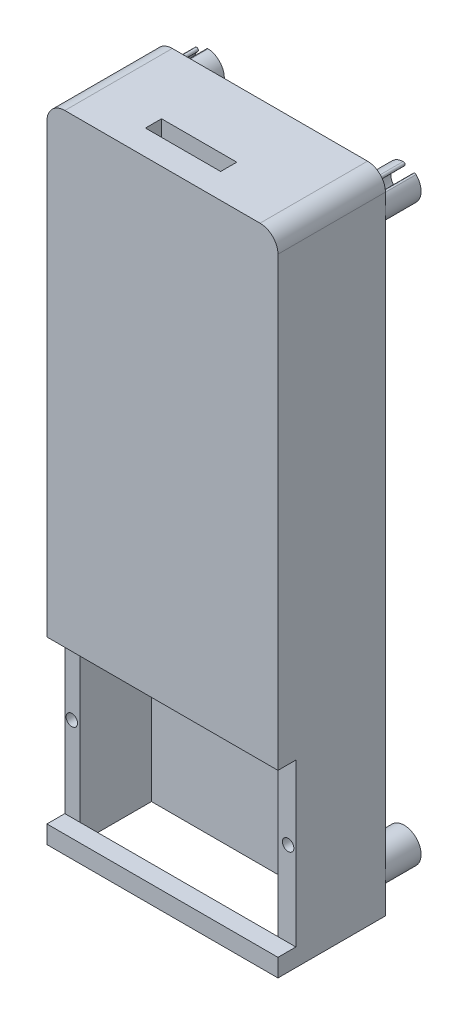
from build123d import *

# Parameters (mm, degrees)
CROQUIS1_W              = 64.5
CROQUIS1_H              = 180
SALIENTE_EXTRUIR1_DEPTH = 30
CROQUIS2_W              = 55.309973817
CROQUIS2_H              = 20
CORTAR_EXTRUIR1_DEPTH   = 155
CORTAR_EXTRUIR2_DEPTH   = 155
CORTAR_EXTRUIR4_DEPTH   = 155
CROQUIS12_R             = 1.6
CORTAR_EXTRUIR8_DEPTH   = 10
SALIENTE_EXTRUIR2_DEPTH = 10
CROQUIS9_W              = 64.5
CROQUIS9_H              = 45.2
CORTAR_EXTRUIR10_DEPTH  = 5
CROQUIS15_R             = 1.6
CORTAR_EXTRUIR11_DEPTH  = 10
CORTAR_EXTRUIR12_REACH  = 187.311
CROQUIS18_W             = 21
CROQUIS18_H             = 4.5


with BuildPart() as part:
    # Croquis1 → Saliente-Extruir1 (new body)
    with BuildSketch(Plane.XY):
        Rectangle(CROQUIS1_W, CROQUIS1_H)
    extrude(amount=SALIENTE_EXTRUIR1_DEPTH)

    # Croquis2 → Cortar-Extruir1 (cut)
    with BuildSketch(Plane.XZ.offset(90)):
        with Locations((-0.404986909, 15)):
            Rectangle(CROQUIS2_W, CROQUIS2_H)
    extrude(amount=-CORTAR_EXTRUIR1_DEPTH, mode=Mode.SUBTRACT)

    # Croquis3 → Cortar-Extruir2 (cut)
    with BuildSketch(Plane(origin=(0, 0, 0), x_dir=(-1, 0, 0), z_dir=(0, 0, -1))):
        with BuildLine():
            Line((-27.25, 90), (-32.25, 90))
            Line((-32.25, 90), (-32.25, 85))
            ThreePointArc((-32.25, 85), (-30.785533906, 88.535533906), (-27.25, 90))
        make_face()
    extrude(amount=-CORTAR_EXTRUIR2_DEPTH, mode=Mode.SUBTRACT)

    # Croquis3_4 → Cortar-Extruir4 (cut)
    with BuildSketch(Plane(origin=(0, 0, 0), x_dir=(-1, 0, 0), z_dir=(0, 0, -1))):
        with BuildLine():
            Line((32.25, 90), (27.25, 90))
            ThreePointArc((27.25, 90), (30.785533906, 88.535533906), (32.25, 85))
            Line((32.25, 85), (32.25, 90))
        make_face()
    extrude(amount=-CORTAR_EXTRUIR4_DEPTH, mode=Mode.SUBTRACT)

    # Croquis12 → Cortar-Extruir8 (cut)
    with BuildSketch(Plane(origin=(0, -90, 0), x_dir=(-1, 0, 0), z_dir=(0, -1, 0))):
        with Locations((30.183391147, -15)):
            Circle(CROQUIS12_R)
        with Locations((-30.15, -15)):
            Circle(CROQUIS12_R)
    extrude(amount=-CORTAR_EXTRUIR8_DEPTH, mode=Mode.SUBTRACT)

    # Croquis14 → Saliente-Extruir2 (add)
    with BuildSketch(Plane(origin=(0, 0, 0), x_dir=(-1, 0, 0), z_dir=(0, 0, -1))):
        with BuildLine():
            ThreePointArc((-30.810899687, 83.538949092), (-25.782194726, 75.745600208), (-27.223730255, 84.90781259))
            ThreePointArc((-27.223730255, 84.90781259), (-27.750555098, 84.433527237), (-27.276269745, 83.906702394))
            ThreePointArc((-27.276269745, 83.906702394), (-26.139605296, 76.682210963), (-30.104786891, 82.827340533))
            ThreePointArc((-30.104786891, 82.827340533), (-30.102039009, 83.53620121), (-30.810899687, 83.538949092))
        make_face()
        with BuildLine():
            ThreePointArc((30.810899687, 83.538949092), (25.782194726, 75.745600208), (27.223730255, 84.90781259))
            ThreePointArc((27.223730255, 84.90781259), (27.750555098, 84.433527237), (27.276269745, 83.906702394))
            ThreePointArc((27.276269745, 83.906702394), (26.139605296, 76.682210963), (30.104786891, 82.827340533))
            ThreePointArc((30.104786891, 82.827340533), (30.102039009, 83.53620121), (30.810899687, 83.538949092))
        make_face()
        with BuildLine():
            ThreePointArc((30.810899687, -83.538949092), (25.782194726, -75.745600208), (27.223730255, -84.90781259))
            ThreePointArc((27.223730255, -84.90781259), (27.750555098, -84.433527237), (27.276269745, -83.906702394))
            ThreePointArc((27.276269745, -83.906702394), (26.139605296, -76.682210963), (30.104786891, -82.827340533))
            ThreePointArc((30.104786891, -82.827340533), (30.102039009, -83.53620121), (30.810899687, -83.538949092))
        make_face()
        with BuildLine():
            ThreePointArc((-30.810899687, -83.538949092), (-25.782194726, -75.745600208), (-27.223730255, -84.90781259))
            ThreePointArc((-27.223730255, -84.90781259), (-27.750555098, -84.433527237), (-27.276269745, -83.906702394))
            ThreePointArc((-27.276269745, -83.906702394), (-26.139605296, -76.682210963), (-30.104786891, -82.827340533))
            ThreePointArc((-30.104786891, -82.827340533), (-30.102039009, -83.53620121), (-30.810899687, -83.538949092))
        make_face()
    extrude(amount=SALIENTE_EXTRUIR2_DEPTH)

    # Croquis9 → Cortar-Extruir10 (cut)
    with BuildSketch(Plane.XY.offset(30)):
        with Locations((0, -62.4)):
            Rectangle(CROQUIS9_W, CROQUIS9_H)
    extrude(amount=-CORTAR_EXTRUIR10_DEPTH, mode=Mode.SUBTRACT)

    # Croquis15 → Cortar-Extruir11 (cut)
    with BuildSketch(Plane.XY.offset(25)):
        with Locations((30.088495575, -61.4)):
            Circle(CROQUIS15_R)
        with Locations((-30.299948917, -61.4)):
            Circle(CROQUIS15_R)
    extrude(amount=-CORTAR_EXTRUIR11_DEPTH, mode=Mode.SUBTRACT)

    # Croquis18 → Cortar-Extruir12 (cut, up to next)
    with BuildSketch(Plane(origin=(0, 90, 0), x_dir=(1, 0, 0), z_dir=(0, 1, 0)), mode=Mode.PRIVATE) as cortar_extruir12_sk1:
        with Locations((-1.25, -20.75)):
            Rectangle(CROQUIS18_W, CROQUIS18_H)
    cortar_extruir12_tool1 = extrude(cortar_extruir12_sk1.sketch, amount=-CORTAR_EXTRUIR12_REACH, mode=Mode.PRIVATE) & part.part
    add(cortar_extruir12_tool1.solids().sort_by_distance((-1.25, 90, 20.75))[0], mode=Mode.SUBTRACT)


solid = part.part
